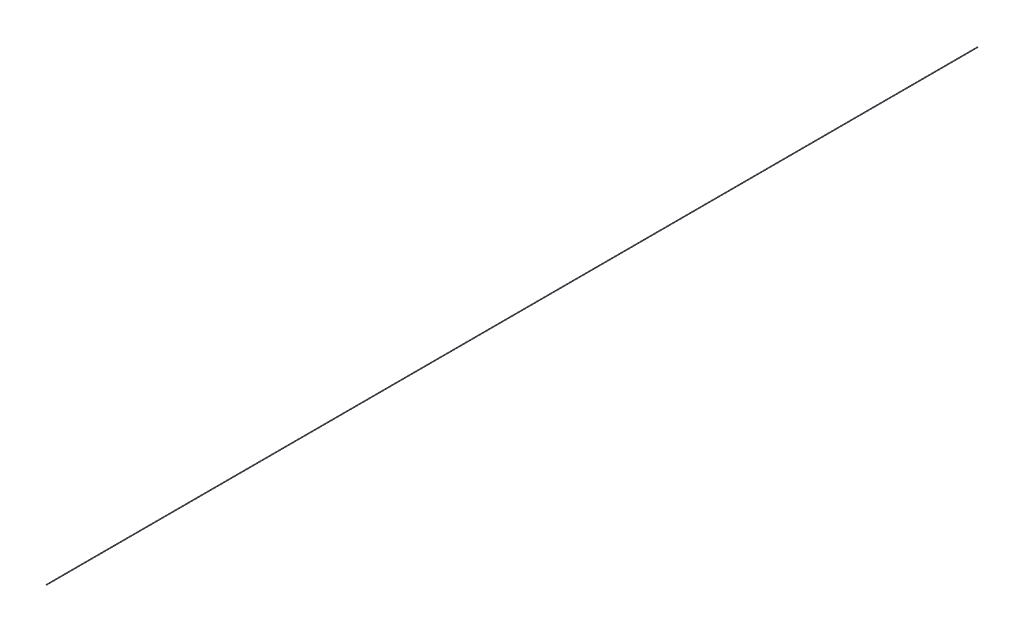
from build123d import *

# Parameters (mm, degrees)
SKETCH1_R           = 0.25
BOSS_EXTRUDE1_DEPTH = 800


with BuildPart() as part:
    # Sketch1 → Boss-Extrude1 (new body)
    with BuildSketch(Plane.XY):
        Circle(SKETCH1_R)
    extrude(amount=BOSS_EXTRUDE1_DEPTH)


solid = part.part
